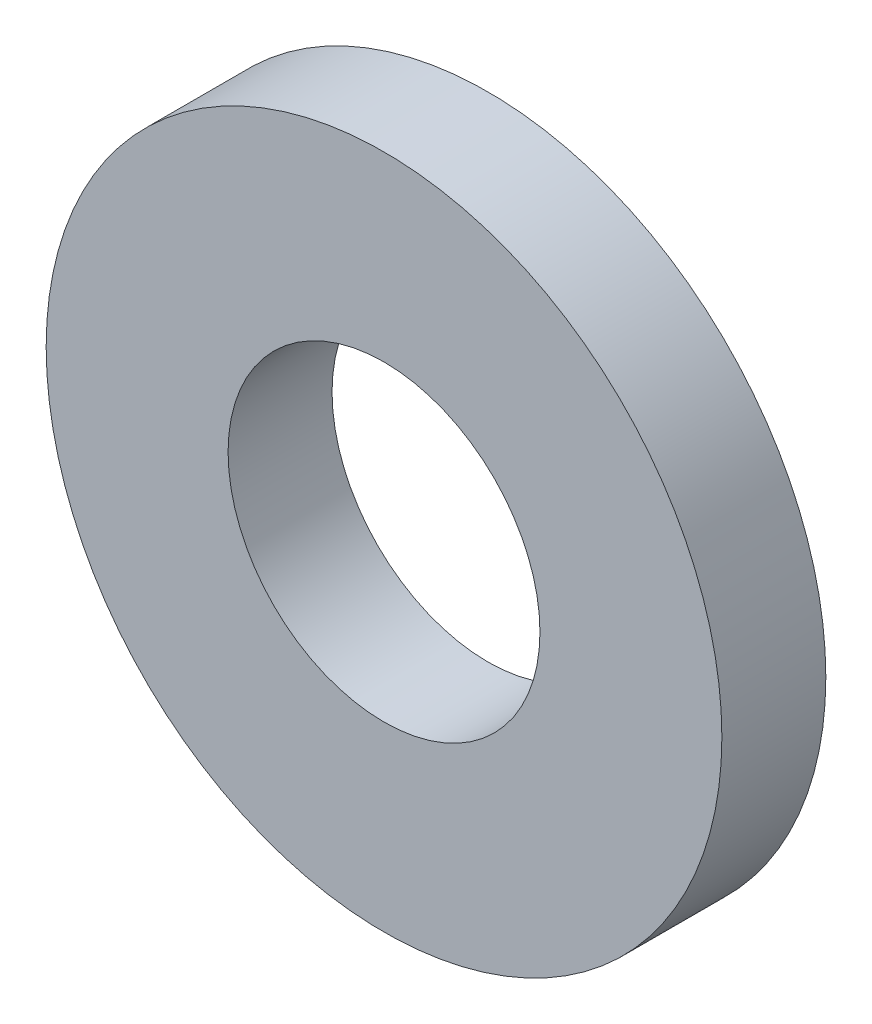
from build123d import *

# Parameters (mm, degrees)
SKETCH1_R           = 41.275
SKETCH1_R_2         = 19.05
BOSS_EXTRUDE1_DEPTH = 12.7


with BuildPart() as part:
    # Sketch1 → Boss-Extrude1 (new body)
    with BuildSketch(Plane.XY):
        Circle(SKETCH1_R)
        Circle(SKETCH1_R_2, mode=Mode.SUBTRACT)
    extrude(amount=BOSS_EXTRUDE1_DEPTH)


solid = part.part
